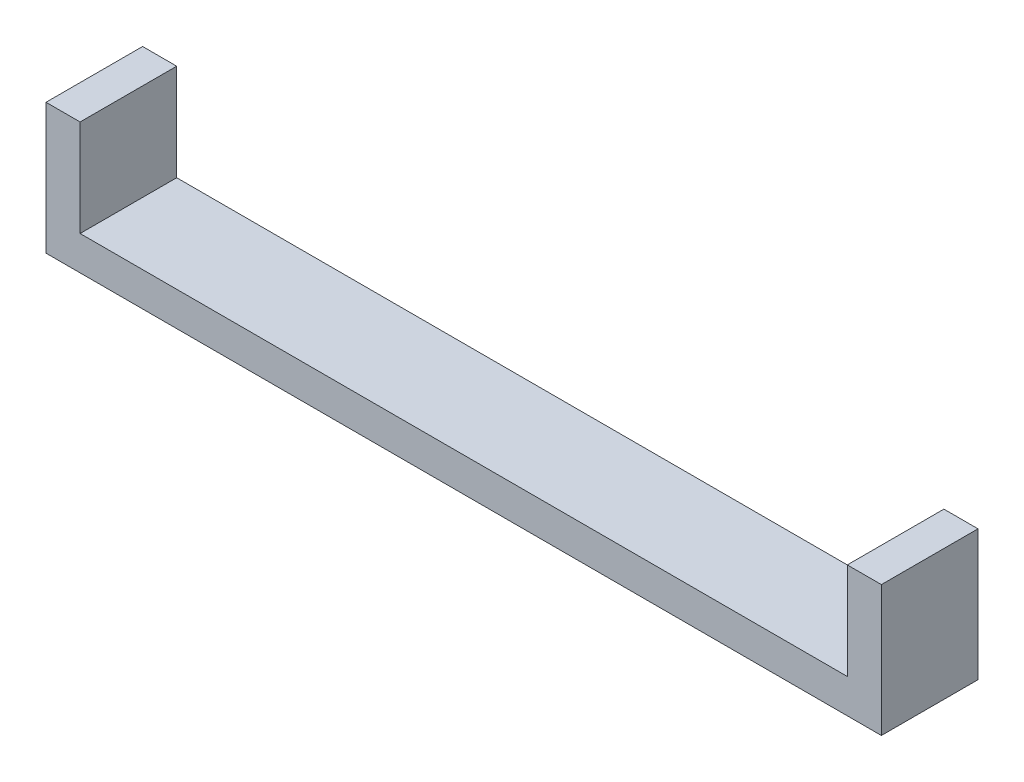
from build123d import *

# Parameters (mm, degrees)
SKETCH1_W            = 8.5
SKETCH1_H            = 8.5
BOSS_EXTRUDE1_DEPTH  = 5
SKETCH2_W            = 8.5
SKETCH2_H            = 8.5
BOSS_EXTRUDE2_DEPTH  = 2
SKETCH3_R            = 1.5
CUT_EXTRUDE1_DEPTH   = 2
SKETCH4_W            = 81.5
SKETCH4_H            = 8.5
BOSS_EXTRUDE3_DEPTH  = 3
SKETCH5_W            = 7
SKETCH5_H            = 8.5
BOSS_EXTRUDE4_DEPTH  = 8.5
CUT_EXTRUDE2_DEPTH   = 5
SKETCH7_R            = 1.5
CUT_EXTRUDE3_DEPTH   = 5
CUT_EXTRUDE4_DEPTH   = 10
SKETCH9_W            = 8.5
SKETCH9_H            = 8.5
SKETCH9_R            = 1.5
BOSS_EXTRUDE5_DEPTH  = 2
CUT_EXTRUDE5_DEPTH   = 2
SKETCH11_W           = 8.5
SKETCH11_H           = 8.5
SKETCH11_R           = 1.5
BOSS_EXTRUDE6_DEPTH  = 2
BOSS_EXTRUDE7_DEPTH  = 5
BOSS_EXTRUDE8_DEPTH  = 5
SKETCH14_W           = 8.5
SKETCH14_H           = 11.5
CUT_EXTRUDE6_DEPTH   = 4
SKETCH15_W           = 8.5
SKETCH15_H           = 11.5
CUT_EXTRUDE7_DEPTH   = 4
SKETCH16_R           = 1.5
CUT_EXTRUDE8_DEPTH   = 4
SKETCH17_R           = 1.5
CUT_EXTRUDE9_DEPTH   = 4
SKETCH19_W           = 8.5
SKETCH19_H           = 8.5
BOSS_EXTRUDE9_DEPTH  = 3
SKETCH20_W           = 8.5
SKETCH20_H           = 8.5
BOSS_EXTRUDE10_DEPTH = 3


with BuildPart() as part:
    # Sketch1 → Boss-Extrude1 (new body)
    with BuildSketch(Plane(origin=(0, 0, 0), x_dir=(0, 0, -1), z_dir=(1, 0, 0))):
        Rectangle(SKETCH1_W, SKETCH1_H)
        Polygon((1.58771324, 2.75), (-1.58771324, 2.75), (-3.175426481, 0), (-1.58771324, -2.75), (1.58771324, -2.75), (3.175426481, 0), align=None, mode=Mode.SUBTRACT)
    extrude(amount=BOSS_EXTRUDE1_DEPTH)

    # Sketch2 → Boss-Extrude2 (add)
    with BuildSketch(Plane.ZY):
        Rectangle(SKETCH2_W, SKETCH2_H)
    extrude(amount=BOSS_EXTRUDE2_DEPTH)

    # Sketch3 → Cut-Extrude1 (cut)
    with BuildSketch(Plane(origin=(0, 0, 0), x_dir=(0, 0, -1), z_dir=(1, 0, 0))):
        Circle(SKETCH3_R)
    extrude(amount=-CUT_EXTRUDE1_DEPTH, mode=Mode.SUBTRACT)

    # Sketch4 → Boss-Extrude3 (add)
    with BuildSketch(Plane.XZ.offset(4.25)):
        with Locations((38.75, 0)):
            Rectangle(SKETCH4_W, SKETCH4_H)
    extrude(amount=BOSS_EXTRUDE3_DEPTH)

    # Sketch5 → Boss-Extrude4 (add)
    with BuildSketch(Plane(origin=(0, -4.25, 0), x_dir=(1, 0, 0), z_dir=(0, 1, 0))):
        with Locations((76, 0)):
            Rectangle(SKETCH5_W, SKETCH5_H)
    extrude(amount=BOSS_EXTRUDE4_DEPTH)

    # Sketch6 → Cut-Extrude2 (cut)
    with BuildSketch(Plane.ZY.offset(-72.5)):
        Polygon((3.175426481, 0), (1.58771324, 2.75), (-1.58771324, 2.75), (-3.175426481, 0), (-1.58771324, -2.75), (1.58771324, -2.75), align=None)
    extrude(amount=-CUT_EXTRUDE2_DEPTH, mode=Mode.SUBTRACT)

    # Sketch7 → Cut-Extrude3 (cut)
    with BuildSketch(Plane.ZY.offset(-77.5)):
        Circle(SKETCH7_R)
    extrude(amount=-CUT_EXTRUDE3_DEPTH, mode=Mode.SUBTRACT)

    # Sketch8 → Cut-Extrude4 (cut)
    with BuildSketch(Plane.ZY.offset(2)):
        Polygon((-1.58771324, 2.75), (1.58771324, 2.75), (3.175426481, 0), (1.58771324, -2.75), (-1.58771324, -2.75), (-3.175426481, 0), align=None)
    extrude(amount=-CUT_EXTRUDE4_DEPTH, mode=Mode.SUBTRACT)

    # Sketch9 → Boss-Extrude5 (add)
    with BuildSketch(Plane(origin=(5, 0, 0), x_dir=(0, 0, -1), z_dir=(1, 0, 0))):
        Rectangle(SKETCH9_W, SKETCH9_H)
        Circle(SKETCH9_R, mode=Mode.SUBTRACT)
    extrude(amount=-BOSS_EXTRUDE5_DEPTH)

    # Sketch10 → Cut-Extrude5 (cut)
    with BuildSketch(Plane(origin=(79.5, 0, 0), x_dir=(0, 0, -1), z_dir=(1, 0, 0))):
        Polygon((-3.175426481, 0), (-1.58771324, 2.75), (1.58771324, 2.75), (3.175426481, 0), (1.58771324, -2.75), (-1.58771324, -2.75), align=None)
    extrude(amount=-CUT_EXTRUDE5_DEPTH, mode=Mode.SUBTRACT)

    # Sketch11 → Boss-Extrude6 (add)
    with BuildSketch(Plane.ZY.offset(-72.5)):
        Rectangle(SKETCH11_W, SKETCH11_H)
        Circle(SKETCH11_R, mode=Mode.SUBTRACT)
    extrude(amount=-BOSS_EXTRUDE6_DEPTH)

    # Sketch12 → Boss-Extrude7 (add)
    with BuildSketch(Plane.ZY.offset(-3)):
        Polygon((-3.175426481, 0), (-1.58771324, 2.75), (1.58771324, 2.75), (3.175426481, 0), (1.58771324, -2.75), (-1.58771324, -2.75), align=None)
    extrude(amount=BOSS_EXTRUDE7_DEPTH)

    # Sketch13 → Boss-Extrude8 (add)
    with BuildSketch(Plane(origin=(74.5, 0, 0), x_dir=(0, 0, -1), z_dir=(1, 0, 0))):
        Polygon((-1.58771324, 2.75), (-3.175426481, 0), (-1.58771324, -2.75), (1.58771324, -2.75), (3.175426481, 0), (1.58771324, 2.75), align=None)
    extrude(amount=BOSS_EXTRUDE8_DEPTH)

    # Sketch14 → Cut-Extrude6 (cut)
    with BuildSketch(Plane.ZY.offset(2)):
        with Locations((0, -1.5)):
            Rectangle(SKETCH14_W, SKETCH14_H)
    extrude(amount=-CUT_EXTRUDE6_DEPTH, mode=Mode.SUBTRACT)

    # Sketch15 → Cut-Extrude7 (cut)
    with BuildSketch(Plane(origin=(79.5, 0, 0), x_dir=(0, 0, -1), z_dir=(1, 0, 0))):
        with Locations((0, -1.5)):
            Rectangle(SKETCH15_W, SKETCH15_H)
    extrude(amount=-CUT_EXTRUDE7_DEPTH, mode=Mode.SUBTRACT)

    # Sketch16 → Cut-Extrude8 (cut)
    with BuildSketch(Plane(origin=(5, 0, 0), x_dir=(0, 0, -1), z_dir=(1, 0, 0))):
        Circle(SKETCH16_R)
    extrude(amount=-CUT_EXTRUDE8_DEPTH, mode=Mode.SUBTRACT)

    # Sketch17 → Cut-Extrude9 (cut)
    with BuildSketch(Plane.ZY.offset(-74.5)):
        Circle(SKETCH17_R)
    extrude(amount=-CUT_EXTRUDE9_DEPTH, mode=Mode.SUBTRACT)

    # Sketch19 → Boss-Extrude9 (add)
    with BuildSketch(Plane(origin=(5, 0, 0), x_dir=(0, 0, -1), z_dir=(1, 0, 0))):
        Rectangle(SKETCH19_W, SKETCH19_H)
    extrude(amount=-BOSS_EXTRUDE9_DEPTH)

    # Sketch20 → Boss-Extrude10 (add)
    with BuildSketch(Plane.ZY.offset(-72.5)):
        Rectangle(SKETCH20_W, SKETCH20_H)
    extrude(amount=-BOSS_EXTRUDE10_DEPTH)


solid = part.part
